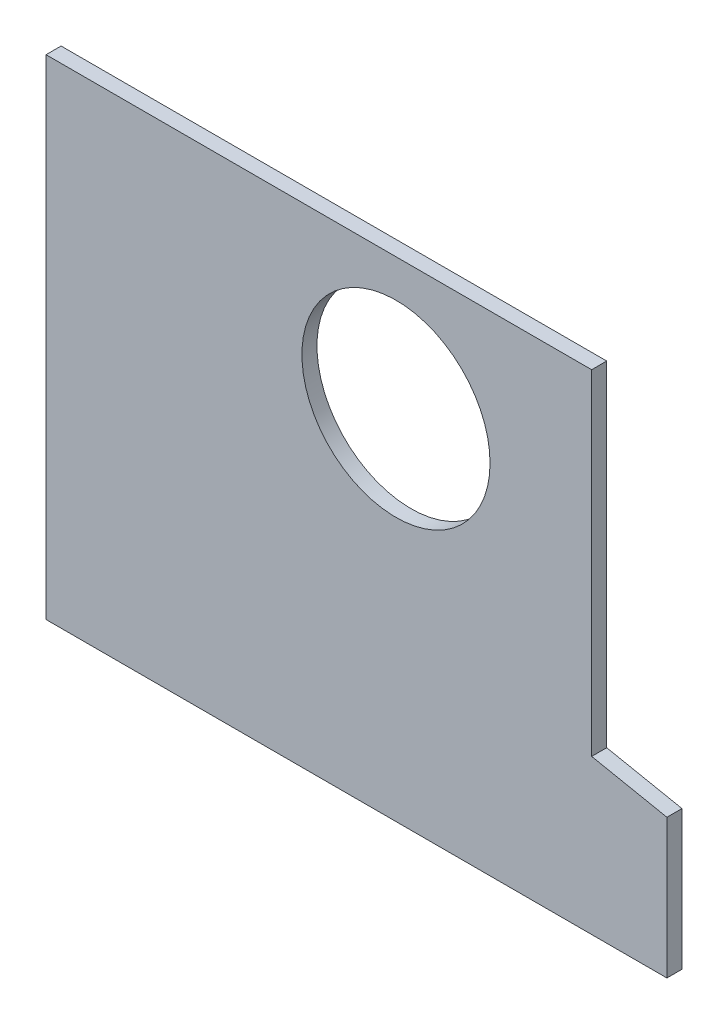
from build123d import *

# Parameters (mm, degrees)
SKETCH1_R           = 25
BOSS_EXTRUDE1_DEPTH = 4


with BuildPart() as part:
    # Sketch1 → Boss-Extrude1 (new body)
    with BuildSketch(Plane.XY):
        Polygon((-82.5, 0), (82.5, 0), (82.5, 37), (62.5, 41), (62.5, 130), (-82.5, 130), align=None)
        with Locations((10.5, 95)):
            Circle(SKETCH1_R, mode=Mode.SUBTRACT)
    extrude(amount=BOSS_EXTRUDE1_DEPTH)


solid = part.part
